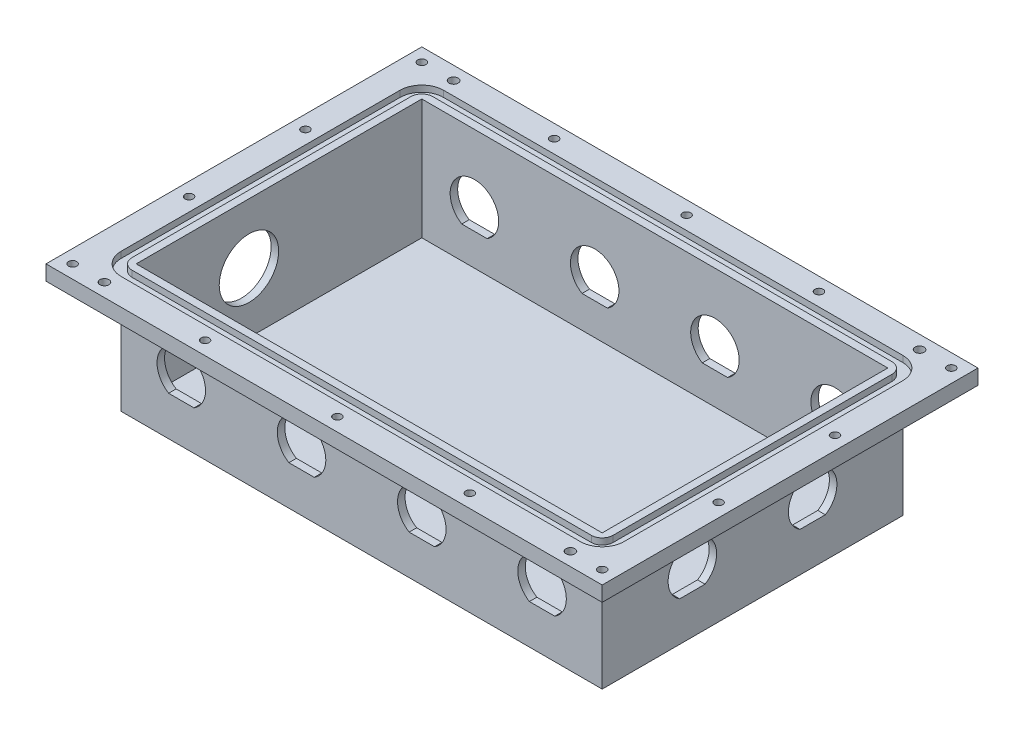
from build123d import *

# Parameters (mm, degrees)
SKETCH1_W             = 203.2
SKETCH1_H             = 127
BOSS_EXTRUDE1_DEPTH   = 53.975
SKETCH2_W             = 196.85
SKETCH2_H             = 120.65
CUT_EXTRUDE1_DEPTH    = 50.8
SKETCH4_W             = 234.95
SKETCH4_H             = 158.75
SKETCH4_W_2           = 203.2
SKETCH4_H_2           = 127
BOSS_EXTRUDE2_DEPTH   = 6.35
SKETCH7_W             = 212.4456
SKETCH7_H             = 136.2456
SKETCH7_W_2           = 203.2
SKETCH7_H_2           = 127
CUT_EXTRUDE2_DEPTH    = 2.6416
F_8_32_TAPPED_HOLE1_D = 3.4544
FILLET3_R             = 4.6228
FILLET4_R             = 9.2456
CUT_EXTRUDE5_DEPTH    = 143.875
CUT_EXTRUDE6_REACH    = 221.075
CUT_EXTRUDE7_REACH    = 221.075
SKETCH13_R            = 12.55395
F_6_CLEARANCE_HOLE1_D = 3.7973


with BuildPart() as part:
    # Sketch1 → Boss-Extrude1 (new body)
    with BuildSketch(Plane(origin=(0, 0, 0), x_dir=(1, 0, 0), z_dir=(0, 1, 0))):
        Rectangle(SKETCH1_W, SKETCH1_H)
    extrude(amount=BOSS_EXTRUDE1_DEPTH)

    # Sketch2 → Cut-Extrude1 (cut)
    with BuildSketch(Plane(origin=(0, 53.975, 0), x_dir=(1, 0, 0), z_dir=(0, 1, 0))):
        Rectangle(SKETCH2_W, SKETCH2_H)
    extrude(amount=-CUT_EXTRUDE1_DEPTH, mode=Mode.SUBTRACT)

    # Sketch4 → Boss-Extrude2 (add)
    with BuildSketch(Plane(origin=(0, 53.975, 0), x_dir=(1, 0, 0), z_dir=(0, 1, 0))):
        Rectangle(SKETCH4_W, SKETCH4_H)
        Rectangle(SKETCH4_W_2, SKETCH4_H_2, mode=Mode.SUBTRACT)
    extrude(amount=-BOSS_EXTRUDE2_DEPTH)

    # Sketch7 → Cut-Extrude2 (cut)
    with BuildSketch(Plane(origin=(0, 53.975, 0), x_dir=(1, 0, 0), z_dir=(0, 1, 0))):
        Rectangle(SKETCH7_W, SKETCH7_H)
        Rectangle(SKETCH7_W_2, SKETCH7_H_2, mode=Mode.SUBTRACT)
    extrude(amount=-CUT_EXTRUDE2_DEPTH, mode=Mode.SUBTRACT)

    # #8-32 Tapped Hole1 (through all)
    with Locations(Plane(origin=(0, 53.975, 0), x_dir=(1, 0, 0), z_dir=(0, 1, 0))):
        with Locations((55.92445, 73.7489), (111.8489, 73.7489), (111.8489, 24.582966667), (0, 73.7489), (111.8489, -24.582966667), (111.8489, -73.7489), (55.92445, -73.7489), (0, -73.7489), (-55.92445, -73.7489), (-111.8489, -73.7489), (-111.8489, -24.582966667), (-111.8489, 24.582966667), (-111.8489, 73.7489), (-55.92445, 73.7489)):
            Hole(F_8_32_TAPPED_HOLE1_D / 2)

    # Fillet3
    fillet3_edges = [part.edges().sort_by_distance(p)[0] for p in [
        (-101.6, 52.6542, -63.5),
        (101.6, 52.6542, -63.5),
        (101.6, 52.6542, 63.5),
        (-101.6, 52.6542, 63.5),
    ]]
    fillet(fillet3_edges, radius=FILLET3_R)

    # Fillet4
    fillet4_edges = [part.edges().sort_by_distance(p)[0] for p in [
        (-106.2228, 52.6542, -68.1228),
        (106.2228, 52.6542, -68.1228),
        (106.2228, 52.6542, 68.1228),
        (-106.2228, 52.6542, 68.1228),
    ]]
    fillet(fillet4_edges, radius=FILLET4_R)

    # Sketch10 → Cut-Extrude5 (cut, through all)
    with BuildSketch(Plane.XY.offset(63.5)):
        with BuildLine():
            ThreePointArc((-70.843294161, 16.6624), (-76.2, 35.6489), (-81.556705839, 16.6624))
            Line((-81.556705839, 16.6624), (-70.843294161, 16.6624))
        make_face()
        with BuildLine():
            ThreePointArc((81.556705839, 16.6624), (76.2, 35.6489), (70.843294161, 16.6624))
            Line((70.843294161, 16.6624), (81.556705839, 16.6624))
        make_face()
        with BuildLine():
            ThreePointArc((30.756705839, 16.6624), (25.4, 35.6489), (20.043294161, 16.6624))
            Line((20.043294161, 16.6624), (30.756705839, 16.6624))
        make_face()
        with BuildLine():
            ThreePointArc((-20.043294161, 16.6624), (-25.4, 35.6489), (-30.756705839, 16.6624))
            Line((-30.756705839, 16.6624), (-20.043294161, 16.6624))
        make_face()
    extrude(amount=-CUT_EXTRUDE5_DEPTH, mode=Mode.SUBTRACT)

    # Sketch12 → Cut-Extrude6 (cut, up to next)
    with BuildSketch(Plane(origin=(101.6, 0, 0), x_dir=(0, 0, -1), z_dir=(1, 0, 0)), mode=Mode.PRIVATE) as cut_extrude6_sk1:
        with BuildLine():
            ThreePointArc((-20.043294161, 16.6624), (-25.4, 35.6489), (-30.756705839, 16.6624))
            Line((-30.756705839, 16.6624), (-20.043294161, 16.6624))
        make_face()
    cut_extrude6_tool1 = extrude(cut_extrude6_sk1.sketch, amount=-CUT_EXTRUDE6_REACH, mode=Mode.PRIVATE) & part.part
    add(cut_extrude6_tool1.solids().sort_by_distance((101.6, 25.721198, 25.4))[0], mode=Mode.SUBTRACT)
    # Sketch12 → Cut-Extrude6 (cut, up to next)
    with BuildSketch(Plane(origin=(101.6, 0, 0), x_dir=(0, 0, -1), z_dir=(1, 0, 0)), mode=Mode.PRIVATE) as cut_extrude6_sk2:
        with BuildLine():
            ThreePointArc((30.756705839, 16.6624), (25.4, 35.6489), (20.043294161, 16.6624))
            Line((20.043294161, 16.6624), (30.756705839, 16.6624))
        make_face()
    cut_extrude6_tool2 = extrude(cut_extrude6_sk2.sketch, amount=-CUT_EXTRUDE6_REACH, mode=Mode.PRIVATE) & part.part
    add(cut_extrude6_tool2.solids().sort_by_distance((101.6, 25.721198, -25.4))[0], mode=Mode.SUBTRACT)

    # Sketch13 → Cut-Extrude7 (cut, up to next)
    with BuildSketch(Plane.ZY.offset(101.6), mode=Mode.PRIVATE) as cut_extrude7_sk1:
        with Locations((12.7, 28.575)):
            Circle(SKETCH13_R)
    cut_extrude7_tool1 = extrude(cut_extrude7_sk1.sketch, amount=-CUT_EXTRUDE7_REACH, mode=Mode.PRIVATE) & part.part
    add(cut_extrude7_tool1.solids().sort_by_distance((-101.6, 28.575, 12.7))[0], mode=Mode.SUBTRACT)

    # #6 Clearance Hole1 (through all)
    with Locations(Plane(origin=(0, 47.625, 0), x_dir=(-1, 0, 0), z_dir=(0, -1, 0))):
        with Locations((-98.425, 73.7489), (-98.425, -73.7489), (98.425, -73.7489), (98.425, 73.7489)):
            Hole(F_6_CLEARANCE_HOLE1_D / 2)


solid = part.part
